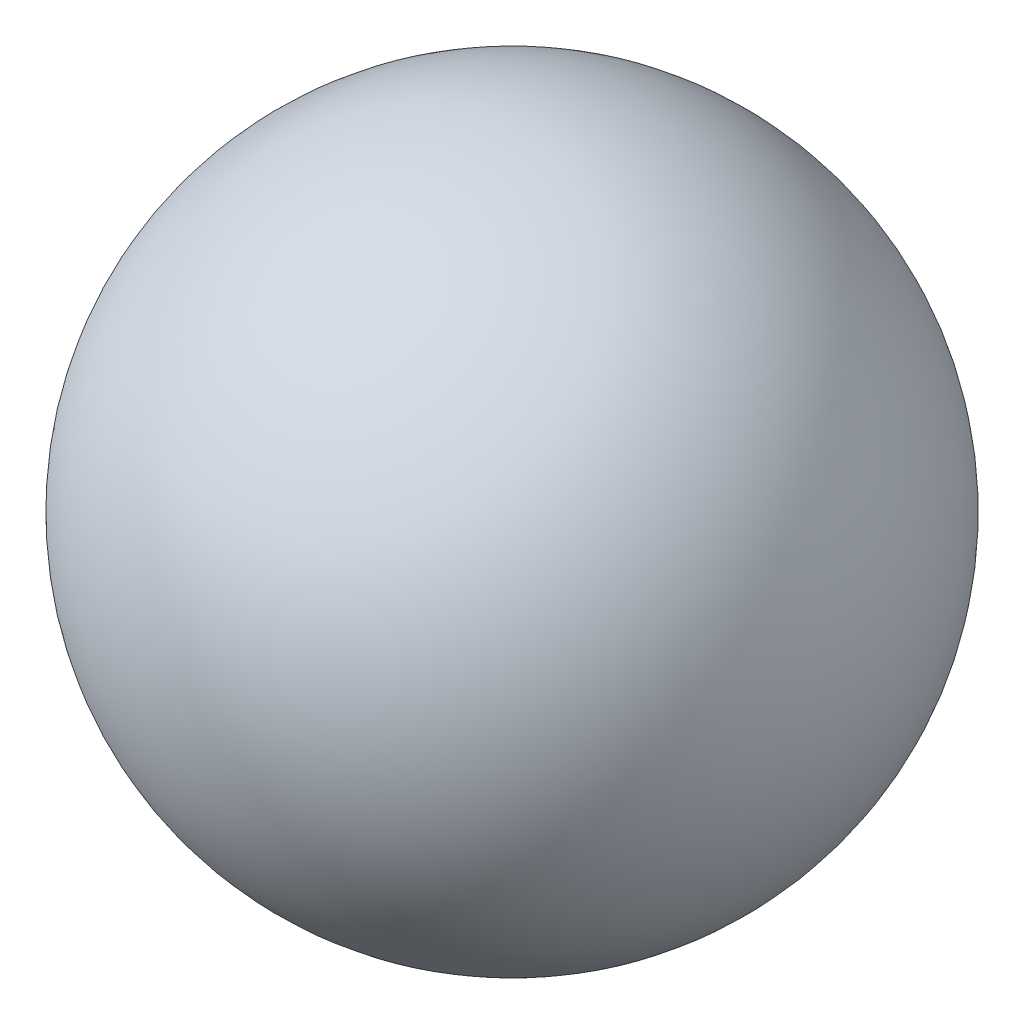
from build123d import *


with BuildPart() as part:
    # Sketch1 → Revolve1 (revolve)
    with BuildSketch(Plane.XY):
        with BuildLine():
            Line((1.54647994, 41.675353269), (1.54647994, -38.324646731))
            ThreePointArc((1.54647994, -38.324646731), (41.54647994, 1.675353269), (1.54647994, 41.675353269))
        make_face()
    revolve(axis=Axis((1.54647994, 41.675353269, 0), (0, -1, 0)))


solid = part.part
